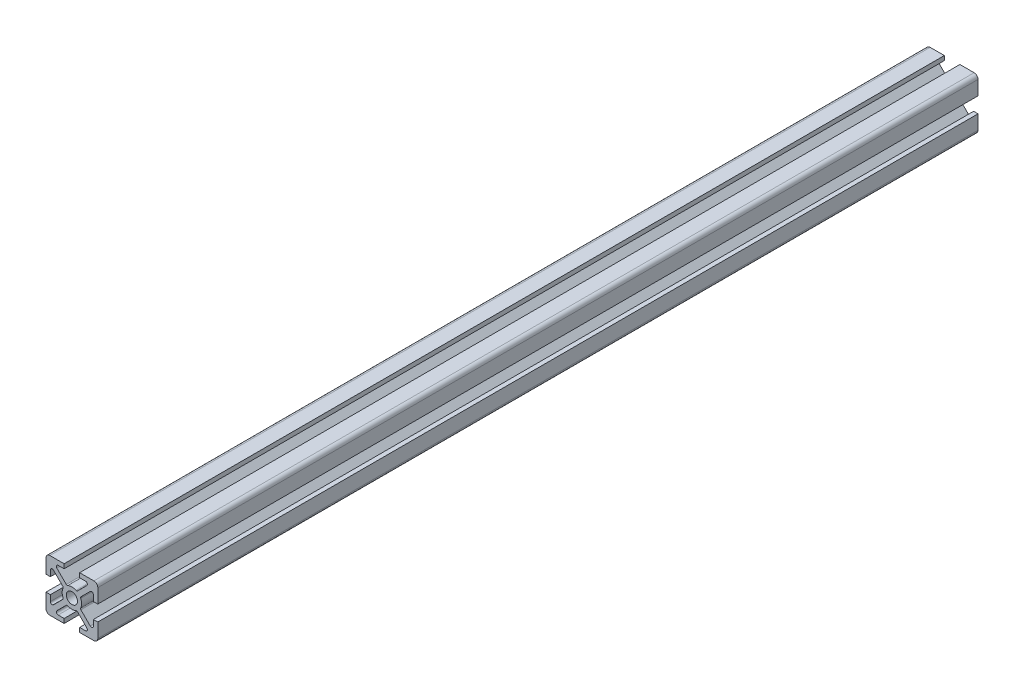
from build123d import *

# Parameters (mm, degrees)
ESQUISSE1_R        = 2.15
BOSS_EXTRU_1_DEPTH = 340


with BuildPart() as part:
    # Esquisse1 → Boss.-Extru.1 (new body)
    with BuildSketch(Plane.XY):
        with BuildLine():
            Line((-3, 10), (-8.5, 10))
            ThreePointArc((-8.5, 10), (-9.560660172, 9.560660172), (-10, 8.5))
            Line((-10, 8.5), (-10, 3))
            Line((-10, 3), (-8.300000103, 3))
            Line((-8.300000103, 3), (-8.300000103, 5.299391013))
            ThreePointArc((-8.300000103, 5.299391013), (-7.867878523, 5.946106661), (-7.105025403, 5.794365741))
            Line((-7.105025403, 5.794365741), (-3.486125569, 2.175465907))
            ThreePointArc((-3.486125569, 2.175465907), (-3.346986783, 1.907085393), (-3.38795202, 1.607569866))
            ThreePointArc((-3.38795202, 1.607569866), (-3.749999968, 1.37e-07), (-3.387952137, -1.607569618))
            ThreePointArc((-3.387952137, -1.607569618), (-3.346986918, -1.907085124), (-3.486125693, -2.175465617))
            Line((-3.486125693, -2.175465617), (-7.10502539, -5.794365497))
            ThreePointArc((-7.10502539, -5.794365497), (-7.867878514, -5.946106433), (-8.300000103, -5.299390782))
            Line((-8.300000103, -5.299390782), (-8.300000103, -3))
            Line((-8.300000103, -3), (-10, -3))
            Line((-10, -3), (-10, -8.5))
            ThreePointArc((-10, -8.5), (-9.560660172, -9.560660172), (-8.5, -10))
            Line((-8.5, -10), (-3, -10))
            Line((-3, -10), (-3, -8.29999992))
            Line((-3, -8.29999992), (-5.299390173, -8.29999992))
            ThreePointArc((-5.299390173, -8.29999992), (-5.94610582, -7.867878342), (-5.794364905, -7.105025224))
            Line((-5.794364905, -7.105025224), (-2.175465502, -3.486125765))
            ThreePointArc((-2.175465502, -3.486125765), (-1.907085014, -3.346986981), (-1.607569506, -3.38795219))
            ThreePointArc((-1.607569506, -3.38795219), (1.99e-07, -3.749999968), (1.607569866, -3.38795202))
            ThreePointArc((1.607569866, -3.38795202), (1.907085393, -3.346986783), (2.175465907, -3.486125569))
            Line((2.175465907, -3.486125569), (5.794365558, -7.10502522))
            ThreePointArc((5.794365558, -7.10502522), (5.946106478, -7.86787834), (5.29939083, -8.29999992))
            Line((5.29939083, -8.29999992), (3, -8.29999992))
            Line((3, -8.29999992), (3, -10))
            Line((3, -10), (8.499999896, -10))
            ThreePointArc((8.499999896, -10), (9.560660068, -9.560660172), (9.999999896, -8.5))
            Line((9.999999896, -8.5), (9.999999896, -3))
            Line((9.999999896, -3), (8.300000103, -3))
            Line((8.300000103, -3), (8.300000103, -5.299391569))
            ThreePointArc((8.300000103, -5.299391569), (7.867878509, -5.946107222), (7.105025381, -5.794366275))
            Line((7.105025381, -5.794366275), (3.486125475, -2.175466057))
            ThreePointArc((3.486125475, -2.175466057), (3.346986701, -1.907085538), (3.38795195, -1.607570012))
            ThreePointArc((3.38795195, -1.607570012), (3.658368452, -0.823917488), (3.749999968, 0))
            ThreePointArc((3.749999968, 0), (3.658368507, 0.823917244), (3.387952165, 1.607569559))
            ThreePointArc((3.387952165, 1.607569559), (3.346986951, 1.907085066), (3.486125731, 2.175465556))
            Line((3.486125731, 2.175465556), (7.105025399, 5.79436528))
            ThreePointArc((7.105025399, 5.79436528), (7.86787852, 5.946106205), (8.300000103, 5.299390557))
            Line((8.300000103, 5.299390557), (8.300000103, 3))
            Line((8.300000103, 3), (9.999999896, 3))
            Line((9.999999896, 3), (9.999999896, 8.5))
            ThreePointArc((9.999999896, 8.5), (9.560660068, 9.560660172), (8.499999896, 10))
            Line((8.499999896, 10), (3.499999896, 10))
            Line((3.499999896, 10), (3, 10))
            Line((3, 10), (3, 8.29999992))
            Line((3, 8.29999992), (5.299389948, 8.29999992))
            ThreePointArc((5.299389948, 8.29999992), (5.946105592, 7.867878348), (5.794364688, 7.105025232))
            Line((5.794364688, 7.105025232), (2.175465441, 3.486125803))
            ThreePointArc((2.175465441, 3.486125803), (1.907084956, 3.346987014), (1.607569447, 3.387952218))
            ThreePointArc((1.607569447, 3.387952218), (-1.51e-07, 3.749999968), (-1.60756972, 3.387952089))
            ThreePointArc((-1.60756972, 3.387952089), (-1.907085249, 3.346986865), (-2.175465757, 3.486125663))
            Line((-2.175465757, 3.486125663), (-5.794365024, 7.105025241))
            ThreePointArc((-5.794365024, 7.105025241), (-5.946105917, 7.867878353), (-5.299390275, 8.29999992))
            Line((-5.299390275, 8.29999992), (-3, 8.29999992))
            Line((-3, 8.29999992), (-3, 10))
        make_face()
        Circle(ESQUISSE1_R, mode=Mode.SUBTRACT)
    extrude(amount=BOSS_EXTRU_1_DEPTH)


solid = part.part
